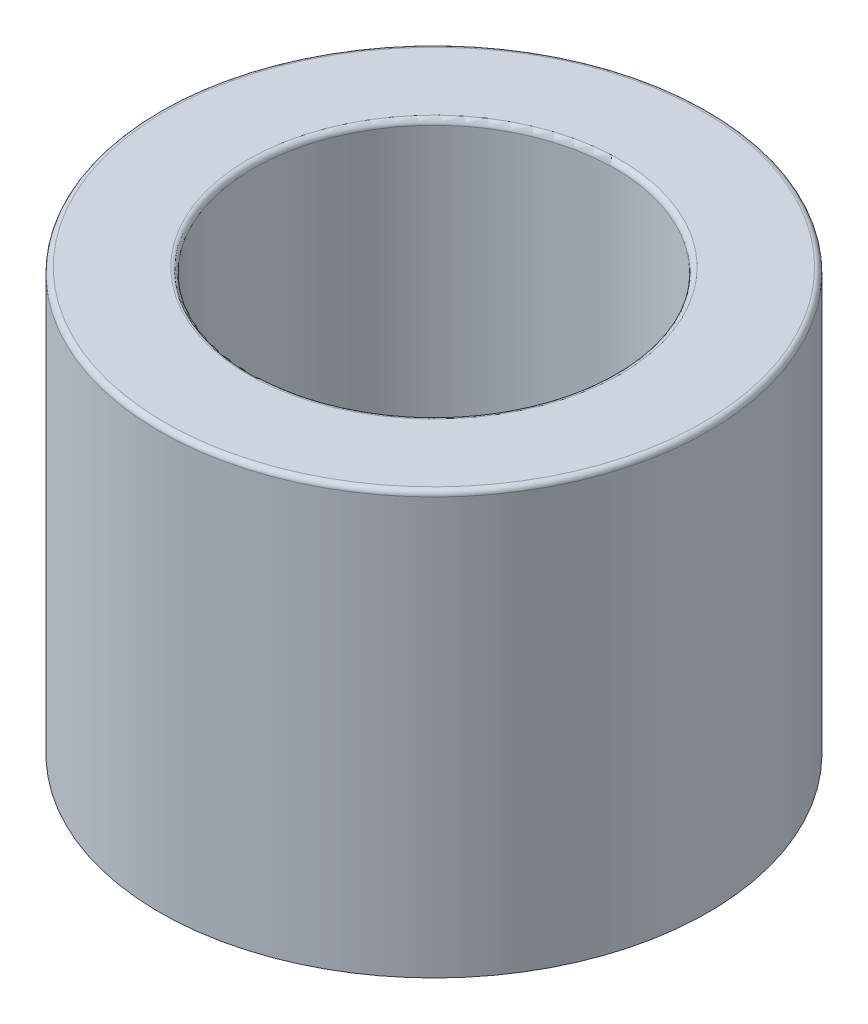
from build123d import *

# Parameters (mm, degrees)
FILLET1_R = 0.142875


with BuildPart() as part:
    # Sketch2 → Revolve1 (revolve)
    with BuildSketch(Plane.XY):
        Polygon((-7.34375, -4.88975), (-7.34375, 6.7625), (-4.7625, 6.7625), (-4.7625, -0.79375), (0.2375, -0.79375), (0.2375, -4.88975), align=None)
    revolve(axis=Axis((0.2375, -0.79375, 0), (0, -1, 0)))

    # Fillet1
    fillet1_edges = [part.edges().sort_by_distance(p)[0] for p in [
        (5.2375, 6.7625, 0),
        (7.81875, 6.7625, 0),
    ]]
    fillet(fillet1_edges, radius=FILLET1_R)


solid = part.part
